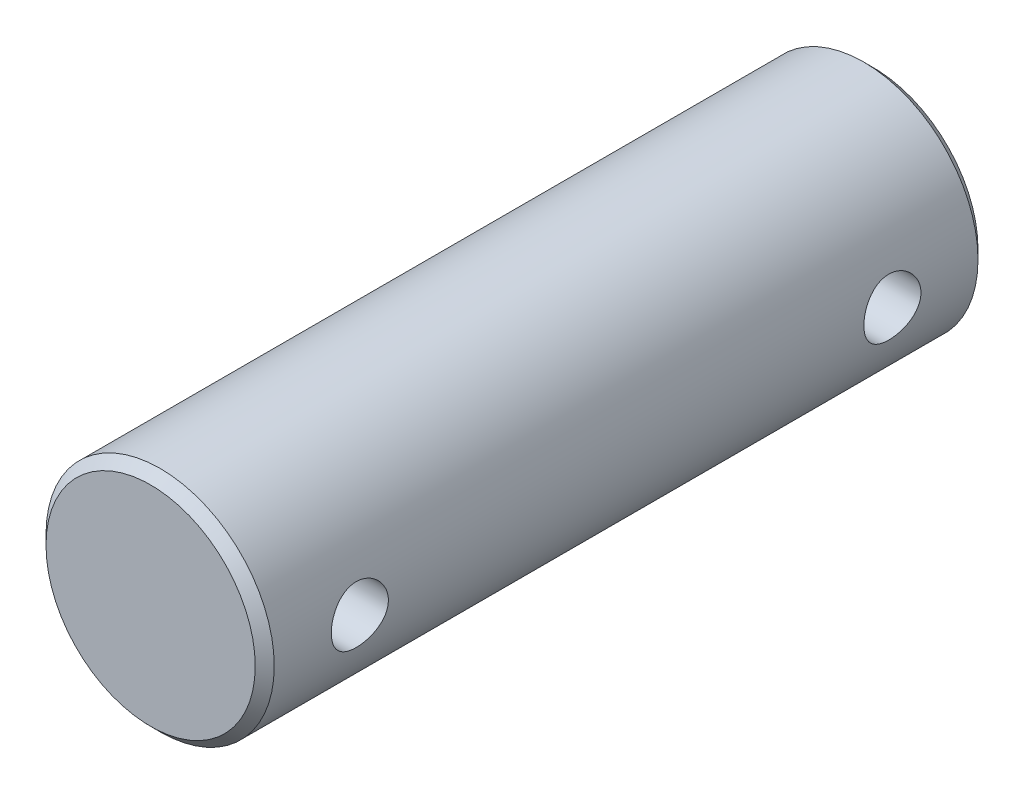
from build123d import *

# Parameters (mm, degrees)
SKETCH1_R            = 6
BODY_DEPTH           = 19
SKETCH2_R            = 1.5
HOLES_DEPTH          = 7
HOLES_DEPTH_BACK     = 7
F_1X_45_CHAMFER_SIZE = 0.5


with BuildPart() as part:
    # Sketch1 → Body (new body, symmetric)
    with BuildSketch(Plane.XY):
        Circle(SKETCH1_R)
    extrude(amount=BODY_DEPTH, both=True)

    # Sketch2 → Holes (cut, two sides)
    with BuildSketch(Plane(origin=(0, 0, 0), x_dir=(0, 0, -1), z_dir=(1, 0, 0))) as holes_sk:
        with Locations((-14, 0)):
            Circle(SKETCH2_R)
        with Locations((14, 0)):
            Circle(SKETCH2_R)
    extrude(amount=HOLES_DEPTH, mode=Mode.SUBTRACT)
    extrude(holes_sk.sketch, amount=-HOLES_DEPTH_BACK, mode=Mode.SUBTRACT)

    # 1x 45 Chamfer
    f_1x_45_chamfer_edges = [part.edges().sort_by_distance(p)[0] for p in [
        (-6, 0, -19),
        (-6, 0, 19),
    ]]
    chamfer(f_1x_45_chamfer_edges, length=F_1X_45_CHAMFER_SIZE)


solid = part.part
